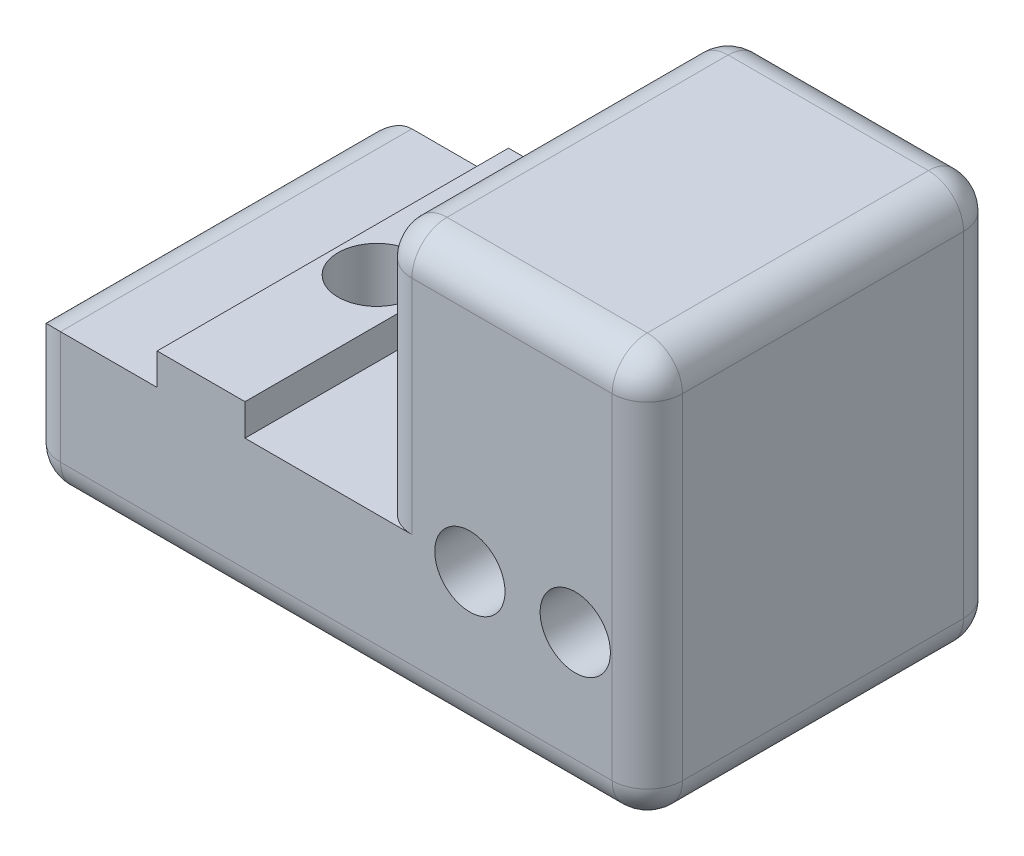
from build123d import *

# Parameters (mm, degrees)
SKETCH1_R           = 2
SKETCH1_R_2         = 3.05
BOSS_EXTRUDE1_DEPTH = 20
SKETCH2_R           = 2.2
CUT_EXTRUDE1_DEPTH  = 27.508
SKETCH2_3_R         = 3.7
SKETCH2_3_R_2       = 2.2
CUT_EXTRUDE2_DEPTH  = 6.435712
BOSS_EXTRUDE2_START = 6.3
SKETCH1_2_R         = 3.05
BOSS_EXTRUDE2_DEPTH = 13.7
FILLET1_R           = 2


with BuildPart() as part:
    # Sketch1 → Boss-Extrude1 (new body)
    with BuildSketch(Plane.XY):
        Polygon((-15.2, -92.57905153), (-50.600589502, -92.57905153), (-50.600589502, -84.143339933), (-43.100589502, -84.143339933), (-43.100589502, -82.343339933), (-38.100589502, -82.343339933), (-38.100589502, -84.143339933), (-30.600589502, -84.143339933), (-30.600589502, -69.503339933), (-15.2, -69.503339933), align=None)
        with Locations((-25.300294751, -84.31585339)):
            Circle(SKETCH1_R, mode=Mode.SUBTRACT)
        with Locations((-19.300294751, -84.31585339)):
            Circle(SKETCH1_R, mode=Mode.SUBTRACT)
        with Locations((-22.300294751, -77.31585339)):
            Circle(SKETCH1_R_2, mode=Mode.SUBTRACT)
    extrude(amount=BOSS_EXTRUDE1_DEPTH)

    # Sketch2 → Cut-Extrude1 (cut)
    with BuildSketch(Plane.XZ.offset(92.57905153)):
        with Locations((-40.600589502, 10)):
            Circle(SKETCH2_R)
    extrude(amount=-CUT_EXTRUDE1_DEPTH, mode=Mode.SUBTRACT)

    # Sketch2_3 → Cut-Extrude2 (cut)
    with BuildSketch(Plane.XZ.offset(92.57905153)):
        with Locations((-40.600589502, 10)):
            Circle(SKETCH2_3_R)
        with Locations((-40.600589502, 10)):
            Circle(SKETCH2_3_R_2, mode=Mode.SUBTRACT)
    extrude(amount=-CUT_EXTRUDE2_DEPTH, mode=Mode.SUBTRACT)

    # Sketch1_2 → Boss-Extrude2 (add)
    with BuildSketch(Plane.XY.offset(BOSS_EXTRUDE2_START)):
        with Locations((-22.300294751, -77.31585339)):
            Circle(SKETCH1_2_R)
    extrude(amount=BOSS_EXTRUDE2_DEPTH)

    # Fillet1
    fillet1_edges = [part.edges().sort_by_distance(p)[0] for p in [
        (-32.900294751, -92.57905153, 0),
        (-50.600589502, -88.361195731, 0),
        (-30.600589502, -76.823339933, 20),
        (-30.600589502, -76.823339933, 0),
        (-22.900294751, -69.503339933, 0),
        (-15.2, -81.041195731, 0),
        (-15.2, -92.57905153, 10),
        (-50.600589502, -92.57905153, 10),
        (-50.600589502, -84.143339933, 10),
        (-30.600589502, -69.503339933, 10),
        (-15.2, -69.503339933, 10),
        (-50.600589502, -88.361195731, 20),
        (-32.900294751, -92.57905153, 20),
        (-15.2, -81.041195731, 20),
        (-22.900294751, -69.503339933, 20),
    ]]
    fillet(fillet1_edges, radius=FILLET1_R)


solid = part.part
